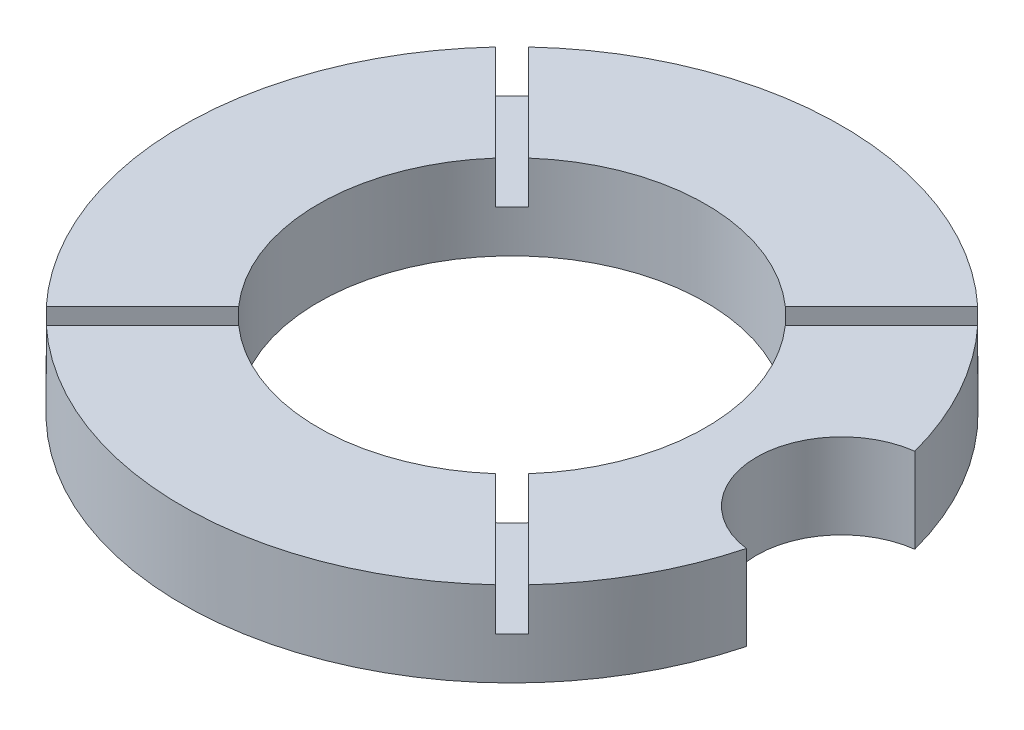
from build123d import *

# Parameters (mm, degrees)
SKETCH1_R           = 49.276
BOSS_EXTRUDE1_DEPTH = 12.7
SKETCH1_10_R        = 28.952599956
CUT_EXTRUDE2_DEPTH  = 13.7
SKETCH2_R           = 12.7
CUT_EXTRUDE3_DEPTH  = 13.7
CUT_EXTRUDE4_DEPTH  = 6.35
CIRPATTERN1_COUNT   = 4


with BuildPart() as part:
    # Sketch1 → Boss-Extrude1 (new body)
    with BuildSketch(Plane(origin=(0, 0, 0), x_dir=(1, 0, 0), z_dir=(0, 1, 0))):
        Circle(SKETCH1_R)
    extrude(amount=BOSS_EXTRUDE1_DEPTH)

    # Sketch1_10 → Cut-Extrude2 (cut, through all)
    with BuildSketch(Plane(origin=(0, 0, 0), x_dir=(1, 0, 0), z_dir=(0, 1, 0))):
        Circle(SKETCH1_10_R)
    extrude(amount=CUT_EXTRUDE2_DEPTH, mode=Mode.SUBTRACT)

    # Sketch2 → Cut-Extrude3 (cut, through all)
    with BuildSketch(Plane(origin=(0, 12.7, 0), x_dir=(1, 0, 0), z_dir=(0, 1, 0))):
        with Locations((49.276, 0)):
            Circle(SKETCH2_R)
    extrude(amount=-CUT_EXTRUDE3_DEPTH, mode=Mode.SUBTRACT)

    # Sketch3 → Cut-Extrude4 (cut)
    with BuildSketch(Plane(origin=(0, 12.7, 0), x_dir=(1, 0, 0), z_dir=(0, 1, 0))):
        with BuildLine():
            ThreePointArc((-33.582072771, 36.060623461), (-34.84339375, 34.84339375), (-36.060623461, 33.582072771))
            Line((-36.060623461, 33.582072771), (-21.674311893, 19.195761203))
            ThreePointArc((-21.674311893, 19.195761203), (-20.472579762, 20.472579762), (-19.195761203, 21.674311893))
            Line((-19.195761203, 21.674311893), (-33.582072771, 36.060623461))
        make_face()
        with BuildLine():
            ThreePointArc((-19.195761203, 21.674311893), (-20.472579762, 20.472579762), (-21.674311893, 19.195761203))
            Line((-21.674311893, 19.195761203), (-19.199787587, 16.721236897))
            Line((-19.199787587, 16.721236897), (-16.721236897, 19.199787587))
            Line((-16.721236897, 19.199787587), (-19.195761203, 21.674311893))
        make_face()
        with BuildLine():
            Line((-19.199787587, 16.721236897), (-21.674311893, 19.195761203))
            ThreePointArc((-21.674311893, 19.195761203), (-10.264632547, -27.071947896), (28.952599956, 0))
            ThreePointArc((28.952599956, 0), (11.884566657, 26.400949218), (-19.195761203, 21.674311893))
            Line((-19.195761203, 21.674311893), (-16.721236897, 19.199787587))
            Line((-16.721236897, 19.199787587), (-19.199787587, 16.721236897))
        make_face()
        with BuildLine():
            Line((-34.897275286, 37.375825976), (-37.375825976, 34.897275286))
            Line((-37.375825976, 34.897275286), (-36.060623461, 33.582072771))
            ThreePointArc((-36.060623461, 33.582072771), (-34.84339375, 34.84339375), (-33.582072771, 36.060623461))
            Line((-33.582072771, 36.060623461), (-34.897275286, 37.375825976))
        make_face()
    cut_extrude4 = extrude(amount=-CUT_EXTRUDE4_DEPTH, mode=Mode.SUBTRACT)

    # CirPattern1: Cut-Extrude4 ×4 about axis
    cirpattern1_axis = Axis((0, 0, 0), (0, 1, 0))
    for i in range(1, CIRPATTERN1_COUNT):
        add(cut_extrude4.rotate(cirpattern1_axis, i * 360 / CIRPATTERN1_COUNT), mode=Mode.SUBTRACT)


solid = part.part
